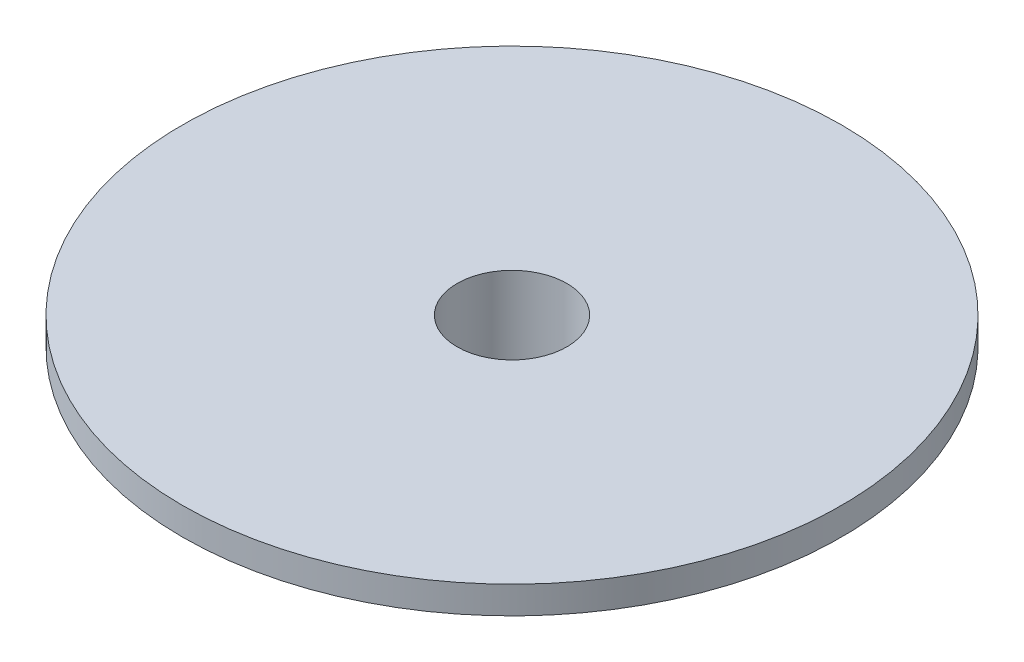
from build123d import *

# Parameters (mm, degrees)
SKETCH1_R                = 2
EXTRUDE1_DEPTH           = 3.125
ESBO_O1_R                = 12
ESBO_O1_R_2              = 2
RESSALTO_EXTRUS_O1_DEPTH = 1
FILETE1_R                = 1


with BuildPart() as part:
    # Sketch1 → Extrude1 (new body)
    with BuildSketch(Plane(origin=(0, 0, 0), x_dir=(1, 0, 0), z_dir=(0, 1, 0))):
        Polygon((3.859462612, 2.263930582), (-0.030890091, 4.474357958), (-3.890352703, 2.210427376), (-3.859462612, -2.263930582), (0.030890091, -4.474357958), (3.890352703, -2.210427376), align=None)
        with Locations(Location((0, 0, 0), (0, 0, 270))):  # turned: the seam where the file's is
            Circle(SKETCH1_R, mode=Mode.SUBTRACT)
    extrude(amount=EXTRUDE1_DEPTH)

    # Esboço1 → Ressalto-extrusão1 (add)
    with BuildSketch(Plane(origin=(0, 3.125, 0), x_dir=(1, 0, 0), z_dir=(0, 1, 0))):
        with Locations(Location((0, 0, 0), (0, 0, 270))):  # turned: the seam where the file's is
            Circle(ESBO_O1_R)
        with Locations(Location((0, 0, 0), (0, 0, 270))):  # turned: the seam where the file's is
            Circle(ESBO_O1_R_2, mode=Mode.SUBTRACT)
    extrude(amount=RESSALTO_EXTRUS_O1_DEPTH)

    # Filete1
    filete1_edges = [part.edges().sort_by_distance(p)[0] for p in [
        (-1.960621397, 3.125, -3.342392667),
        (-3.874907657, 3.125, 0.026751603),
        (-1.91428626, 3.125, 3.36914427),
        (1.960621397, 3.125, 3.342392667),
        (3.874907657, 3.125, -0.026751603),
        (1.91428626, 3.125, -3.36914427),
    ]]
    fillet(filete1_edges, radius=FILETE1_R)


solid = part.part
